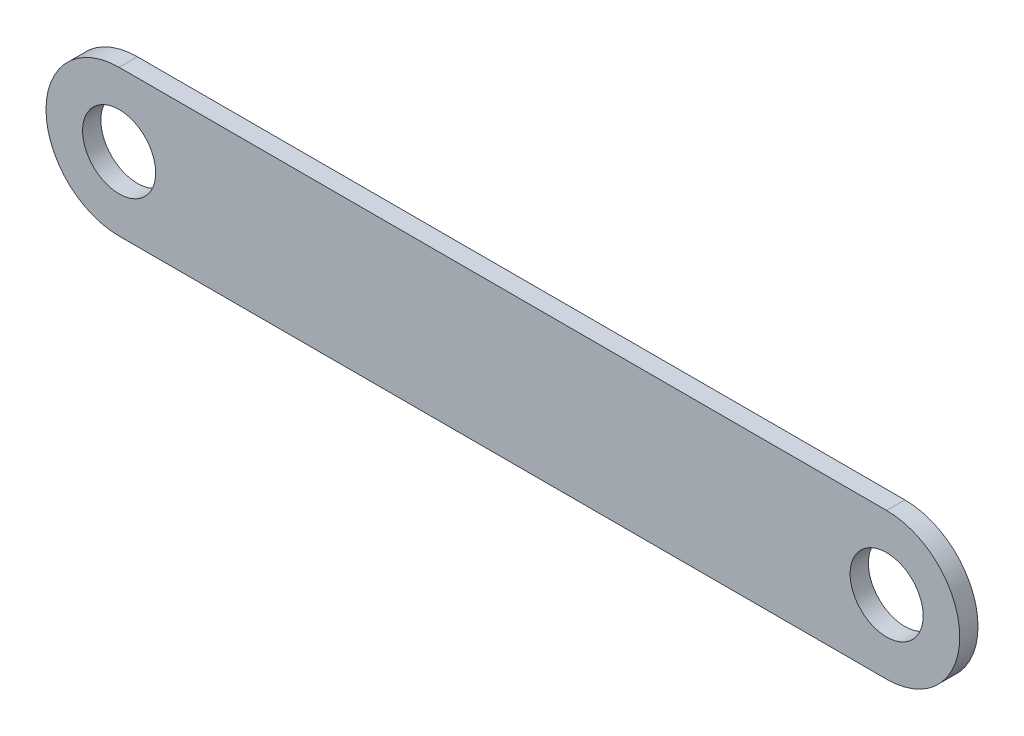
from build123d import *

# Parameters (mm, degrees)
EXTRUDE1_DEPTH     = 5
SKETCH2_R          = 10
CUT_EXTRUDE1_DEPTH = 6


with BuildPart() as part:
    # Sketch1 → Extrude1 (new body)
    with BuildSketch(Plane.XY):
        with BuildLine():
            Line((51.513050076, 21.557056146), (-158.486949924, 21.557056146))
            ThreePointArc((-158.486949924, 21.557056146), (-178.486949924, 1.557056146), (-158.486949924, -18.442943854))
            Line((-158.486949924, -18.442943854), (51.513050076, -18.442943854))
            ThreePointArc((51.513050076, -18.442943854), (71.513050076, 1.557056146), (51.513050076, 21.557056146))
        make_face()
    extrude(amount=EXTRUDE1_DEPTH)

    # Sketch2 → Cut-Extrude1 (cut, through all)
    with BuildSketch(Plane.XY.offset(5)):
        with Locations((-158.486949924, 1.557056146)):
            Circle(SKETCH2_R)
        with Locations((51.513050076, 1.557056146)):
            Circle(SKETCH2_R)
    extrude(amount=-CUT_EXTRUDE1_DEPTH, mode=Mode.SUBTRACT)


solid = part.part
